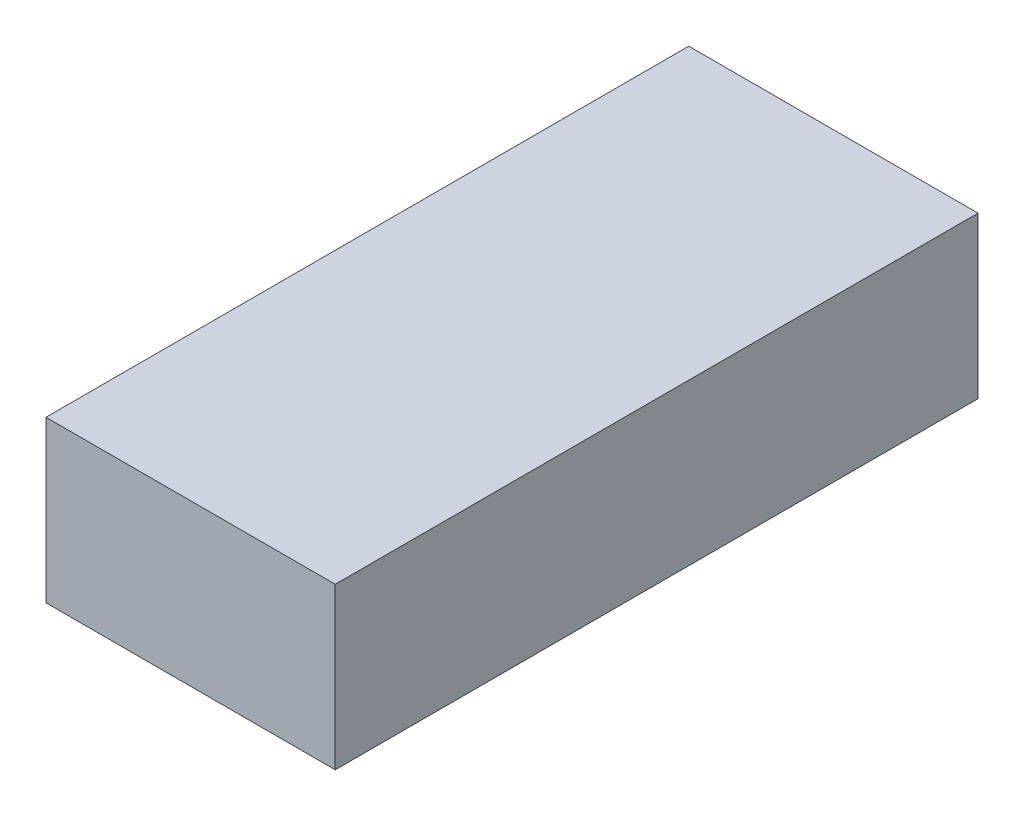
from build123d import *

# Parameters (mm, degrees)
SKETCH1_W           = 4.5
SKETCH1_H           = 10
BOSS_EXTRUDE1_DEPTH = 2.5


with BuildPart() as part:
    # Sketch1 → Boss-Extrude1 (new body)
    with BuildSketch(Plane(origin=(0, 0, 0), x_dir=(1, 0, 0), z_dir=(0, 1, 0))):
        with Locations((2.25, 5)):
            Rectangle(SKETCH1_W, SKETCH1_H)
    extrude(amount=BOSS_EXTRUDE1_DEPTH)


solid = part.part
